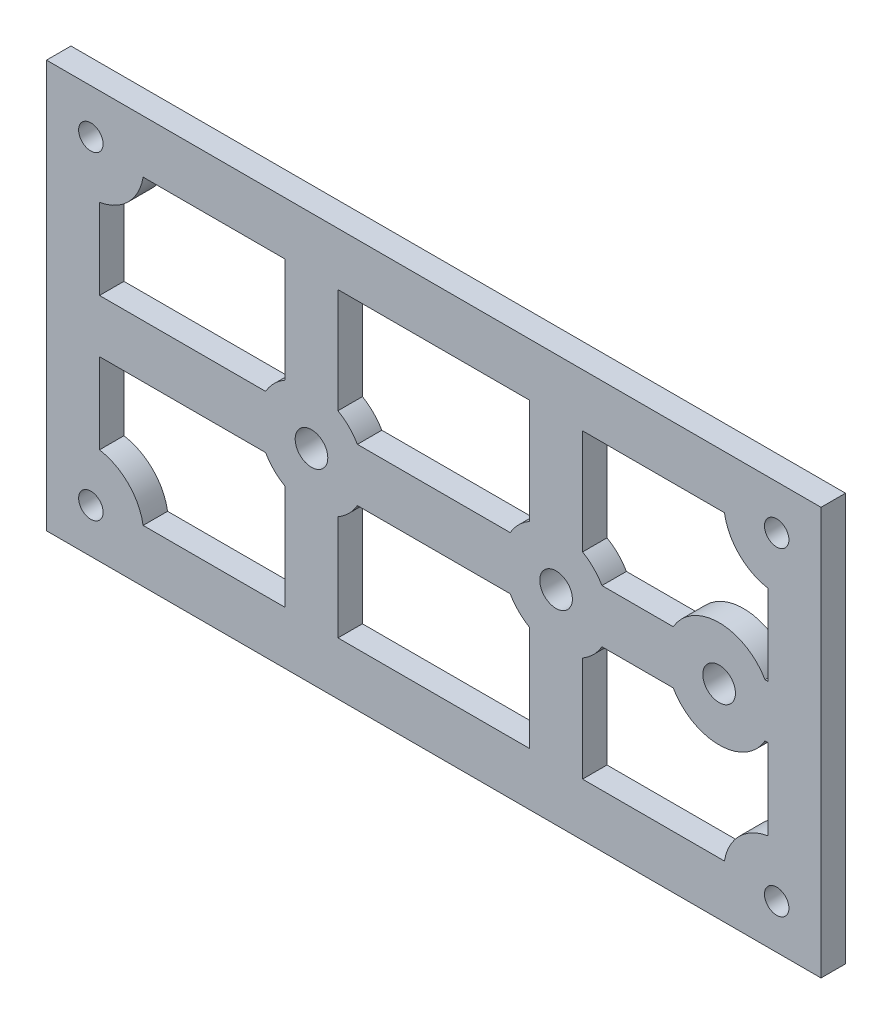
from build123d import *

# Parameters (mm, degrees)
SKETCH2_W               = 95
SKETCH2_H               = 50
BOSS_EXTRUDE1_DEPTH     = 3
SKETCH1_R               = 2
SKETCH1_R_2             = 1.5
CUT_EXTRUDE2_DEPTH      = 4
CUT_EXTRUDE2_DEPTH_BACK = 1


with BuildPart() as part:
    # Sketch2 → Boss-Extrude1 (new body)
    with BuildSketch(Plane.XY):
        Rectangle(SKETCH2_W, SKETCH2_H)
    extrude(amount=BOSS_EXTRUDE1_DEPTH)

    # Sketch1 → Cut-Extrude2 (cut, two sides)
    with BuildSketch(Plane.XY) as cut_extrude2_sk:
        with BuildLine():
            ThreePointArc((18.25, -5.629165125), (19.596194078, -4.596194078), (20.629165125, -3.25))
            Line((20.629165125, -3.25), (29.370834875, -3.25))
            ThreePointArc((29.370834875, -3.25), (35, -6.5), (40.629165125, -3.25))
            Line((40.629165125, -3.25), (41, -3.25))
            Line((41, -3.25), (41, -13.147782503))
            ThreePointArc((41, -13.147782503), (37.464466094, -14.964466094), (35.647782503, -18.5))
            Line((35.647782503, -18.5), (18.25, -18.5))
            Line((18.25, -18.5), (18.25, -5.629165125))
        make_face()
        with BuildLine():
            ThreePointArc((40.629165125, 3.25), (35, 6.5), (29.370834875, 3.25))
            Line((29.370834875, 3.25), (20.629165125, 3.25))
            ThreePointArc((20.629165125, 3.25), (19.596194078, 4.596194078), (18.25, 5.629165125))
            Line((18.25, 5.629165125), (18.25, 18.5))
            Line((18.25, 18.5), (35.647782503, 18.5))
            ThreePointArc((35.647782503, 18.5), (37.464466094, 14.964466094), (41, 13.147782503))
            Line((41, 13.147782503), (41, 3.25))
            Line((41, 3.25), (40.629165125, 3.25))
        make_face()
        with BuildLine():
            ThreePointArc((11.75, 5.629165125), (10.403805922, 4.596194078), (9.370834875, 3.25))
            Line((9.370834875, 3.25), (-9.370834875, 3.25))
            ThreePointArc((-9.370834875, 3.25), (-10.403805922, 4.596194078), (-11.75, 5.629165125))
            Line((-11.75, 5.629165125), (-11.75, 18.5))
            Line((-11.75, 18.5), (11.75, 18.5))
            Line((11.75, 18.5), (11.75, 5.629165125))
        make_face()
        with BuildLine():
            ThreePointArc((-11.75, -5.629165125), (-10.403805922, -4.596194078), (-9.370834875, -3.25))
            Line((-9.370834875, -3.25), (9.370834875, -3.25))
            ThreePointArc((9.370834875, -3.25), (10.403805922, -4.596194078), (11.75, -5.629165125))
            Line((11.75, -5.629165125), (11.75, -18.5))
            Line((11.75, -18.5), (-11.75, -18.5))
            Line((-11.75, -18.5), (-11.75, -5.629165125))
        make_face()
        with Locations((-15, 0)):
            Circle(SKETCH1_R)
        with BuildLine():
            ThreePointArc((-18.25, 5.629165125), (-19.596194078, 4.596194078), (-20.629165125, 3.25))
            Line((-20.629165125, 3.25), (-41, 3.25))
            Line((-41, 3.25), (-41, 13.147782503))
            ThreePointArc((-41, 13.147782503), (-37.464466094, 14.964466094), (-35.647782503, 18.5))
            Line((-35.647782503, 18.5), (-18.25, 18.5))
            Line((-18.25, 18.5), (-18.25, 5.629165125))
        make_face()
        with BuildLine():
            ThreePointArc((-20.629165125, -3.25), (-19.596194078, -4.596194078), (-18.25, -5.629165125))
            Line((-18.25, -5.629165125), (-18.25, -18.5))
            Line((-18.25, -18.5), (-35.647782503, -18.5))
            ThreePointArc((-35.647782503, -18.5), (-37.464466094, -14.964466094), (-41, -13.147782503))
            Line((-41, -13.147782503), (-41, -3.25))
            Line((-41, -3.25), (-20.629165125, -3.25))
        make_face()
        with Locations((42.060660172, -19.560660172)):
            Circle(SKETCH1_R_2)
        with Locations((42.060660172, 19.560660172)):
            Circle(SKETCH1_R_2)
        with Locations((15, 0)):
            Circle(SKETCH1_R)
        with Locations((35, 0)):
            Circle(SKETCH1_R)
        with Locations((-42.060660172, 19.560660172)):
            Circle(SKETCH1_R_2)
        with Locations((-42.060660172, -19.560660172)):
            Circle(SKETCH1_R_2)
    extrude(amount=CUT_EXTRUDE2_DEPTH, mode=Mode.SUBTRACT)
    extrude(cut_extrude2_sk.sketch, amount=-CUT_EXTRUDE2_DEPTH_BACK, mode=Mode.SUBTRACT)


solid = part.part
